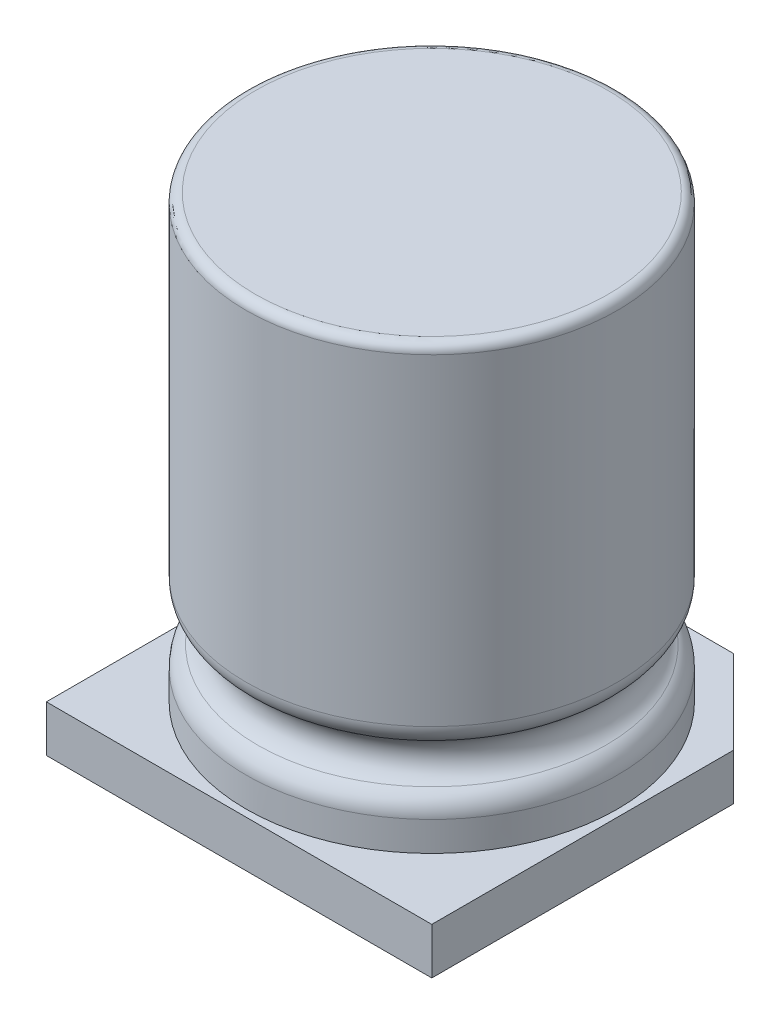
from build123d import *

# Parameters (mm, degrees)
SKETCH1_W           = 8.3
SKETCH1_H           = 8.3
BOSS_EXTRUDE1_DEPTH = 1
SKETCH2_R           = 4
BOSS_EXTRUDE2_DEPTH = 9.5
SKETCH3_R           = 0.5
FILLET1_R           = 0.5
FILLET2_R           = 0.2
CHAMFER1_SIZE       = 1.8


with BuildPart() as part:
    # Sketch1 → Boss-Extrude1 (new body)
    with BuildSketch(Plane(origin=(0, 0, 0), x_dir=(1, 0, 0), z_dir=(0, 1, 0))):
        Rectangle(SKETCH1_W, SKETCH1_H)
    extrude(amount=BOSS_EXTRUDE1_DEPTH)

    # Chamfer1
    chamfer1_edges = [part.edges().sort_by_distance(p)[0] for p in [
        (-4.15, 0.5, -4.15),
        (4.15, 0.5, -4.15),
    ]]
    chamfer(chamfer1_edges, length=CHAMFER1_SIZE)


with BuildPart() as body_2:
    # Sketch2 → Boss-Extrude2 (new body)
    with BuildSketch(Plane(origin=(0, 1, 0), x_dir=(1, 0, 0), z_dir=(0, 1, 0))):
        Circle(SKETCH2_R)
    extrude(amount=BOSS_EXTRUDE2_DEPTH)

    # Sketch3 → Cut-Revolve1 (revolve, cut)
    with BuildSketch(Plane.XY):
        with Locations((4, 2.5)):
            Circle(SKETCH3_R)
    revolve(axis=Axis((0, 10.5, 0), (0, -1, 0)), mode=Mode.SUBTRACT)

    # Fillet1
    fillet1_edges = [body_2.edges().sort_by_distance(p)[0] for p in [
        (-4, 3, 0),
        (-4, 2, 0),
    ]]
    fillet(fillet1_edges, radius=FILLET1_R)

    # Fillet2
    fillet2_edges = [body_2.edges().sort_by_distance(p)[0] for p in [
        (-4, 10.5, 0),
    ]]
    fillet(fillet2_edges, radius=FILLET2_R)


solid = Compound([part.part, body_2.part])
